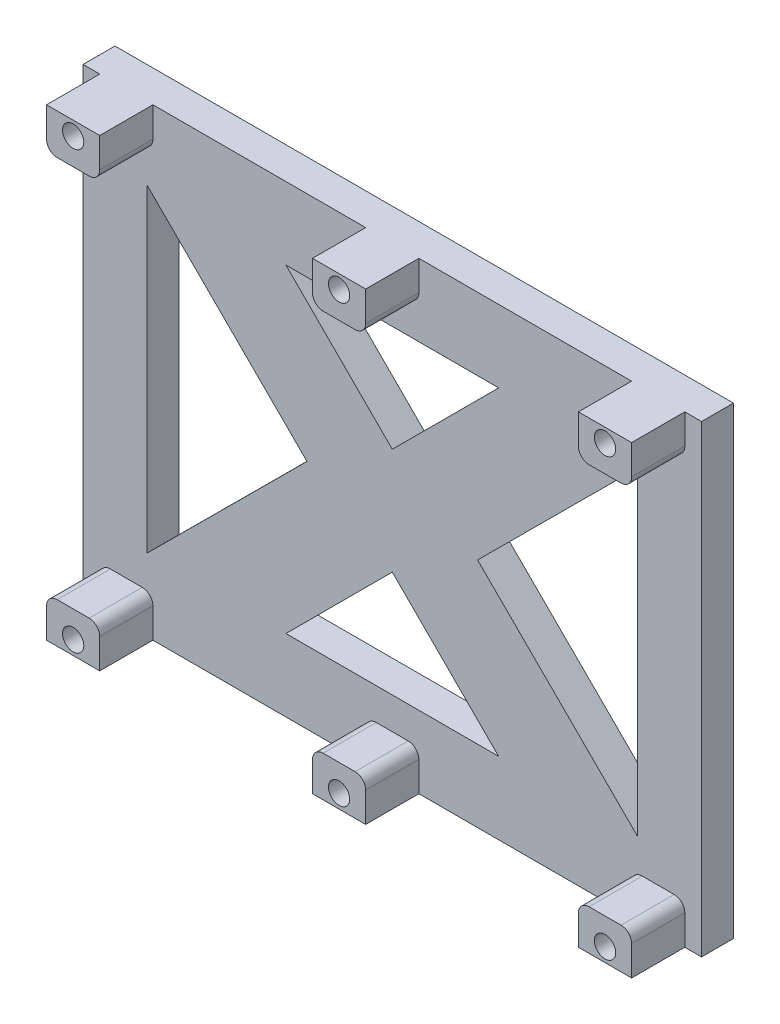
from build123d import *

# Parameters (mm, degrees)
SKETCH1_W           = 58.1426
SKETCH1_H           = 43.5894
BOSS_EXTRUDE1_DEPTH = 3
SKETCH2_R           = 1
BOSS_EXTRUDE2_DEPTH = 5


with BuildPart() as part:
    # Sketch1 → Boss-Extrude1 (new body)
    with BuildSketch(Plane.XY):
        with Locations((29.0713, 21.7947)):
            Rectangle(SKETCH1_W, SKETCH1_H)
        Polygon((6, 36.7947), (6, 6.7947), (21.0529, 21.7947), align=None, mode=Mode.SUBTRACT)
        Polygon((39.0713, 6.7947), (29.0713, 16.7947), (19.0713, 6.7947), align=None, mode=Mode.SUBTRACT)
        Polygon((52.1426, 36.7947), (52.1426, 6.7947), (37.0897, 21.7947), align=None, mode=Mode.SUBTRACT)
        Polygon((19.0713, 36.7947), (39.0713, 36.7947), (29.0713, 26.7947), align=None, mode=Mode.SUBTRACT)
    extrude(amount=BOSS_EXTRUDE1_DEPTH)

    # Sketch2 → Boss-Extrude2 (add)
    with BuildSketch(Plane.XY.offset(3)):
        with BuildLine():
            Line((1.57, 43.5894), (6.57, 43.5894))
            Line((6.57, 43.5894), (6.57, 40.7894))
            ThreePointArc((6.57, 40.7894), (6.277106781, 40.082293219), (5.57, 39.7894))
            Line((5.57, 39.7894), (2.57, 39.7894))
            ThreePointArc((2.57, 39.7894), (1.862893219, 40.082293219), (1.57, 40.7894))
            Line((1.57, 40.7894), (1.57, 43.5894))
        make_face()
        with Locations((4.07, 42.2894)):
            Circle(SKETCH2_R, mode=Mode.SUBTRACT)
        with BuildLine():
            Line((26.57, 43.5894), (31.57, 43.5894))
            Line((31.57, 43.5894), (31.57, 40.7894))
            ThreePointArc((31.57, 40.7894), (31.277106781, 40.082293219), (30.57, 39.7894))
            Line((30.57, 39.7894), (27.57, 39.7894))
            ThreePointArc((27.57, 39.7894), (26.862893219, 40.082293219), (26.57, 40.7894))
            Line((26.57, 40.7894), (26.57, 43.5894))
        make_face()
        with Locations((29.07, 42.2894)):
            Circle(SKETCH2_R, mode=Mode.SUBTRACT)
        with BuildLine():
            Line((51.57, 43.5894), (56.57, 43.5894))
            Line((56.57, 43.5894), (56.57, 40.7894))
            ThreePointArc((56.57, 40.7894), (56.277106781, 40.082293219), (55.57, 39.7894))
            Line((55.57, 39.7894), (52.57, 39.7894))
            ThreePointArc((52.57, 39.7894), (51.862893219, 40.082293219), (51.57, 40.7894))
            Line((51.57, 40.7894), (51.57, 43.5894))
        make_face()
        with Locations((54.07, 42.2894)):
            Circle(SKETCH2_R, mode=Mode.SUBTRACT)
        with BuildLine():
            Line((56.57, 0), (56.57, 2.8))
            ThreePointArc((56.57, 2.8), (56.277106781, 3.507106781), (55.57, 3.8))
            Line((55.57, 3.8), (52.57, 3.8))
            ThreePointArc((52.57, 3.8), (51.862893219, 3.507106781), (51.57, 2.8))
            Line((51.57, 2.8), (51.57, 0))
            Line((51.57, 0), (56.57, 0))
        make_face()
        with Locations((54.07, 1.3)):
            Circle(SKETCH2_R, mode=Mode.SUBTRACT)
        with BuildLine():
            Line((31.57, 0), (31.57, 2.8))
            ThreePointArc((31.57, 2.8), (31.277106781, 3.507106781), (30.57, 3.8))
            Line((30.57, 3.8), (27.57, 3.8))
            ThreePointArc((27.57, 3.8), (26.862893219, 3.507106781), (26.57, 2.8))
            Line((26.57, 2.8), (26.57, 0))
            Line((26.57, 0), (31.57, 0))
        make_face()
        with Locations((29.07, 1.3)):
            Circle(SKETCH2_R, mode=Mode.SUBTRACT)
        with BuildLine():
            Line((6.57, 0), (6.57, 2.8))
            ThreePointArc((6.57, 2.8), (6.277106781, 3.507106781), (5.57, 3.8))
            Line((5.57, 3.8), (2.57, 3.8))
            ThreePointArc((2.57, 3.8), (1.862893219, 3.507106781), (1.57, 2.8))
            Line((1.57, 2.8), (1.57, 0))
            Line((1.57, 0), (6.57, 0))
        make_face()
        with Locations((4.07, 1.3)):
            Circle(SKETCH2_R, mode=Mode.SUBTRACT)
    extrude(amount=BOSS_EXTRUDE2_DEPTH)


solid = part.part
